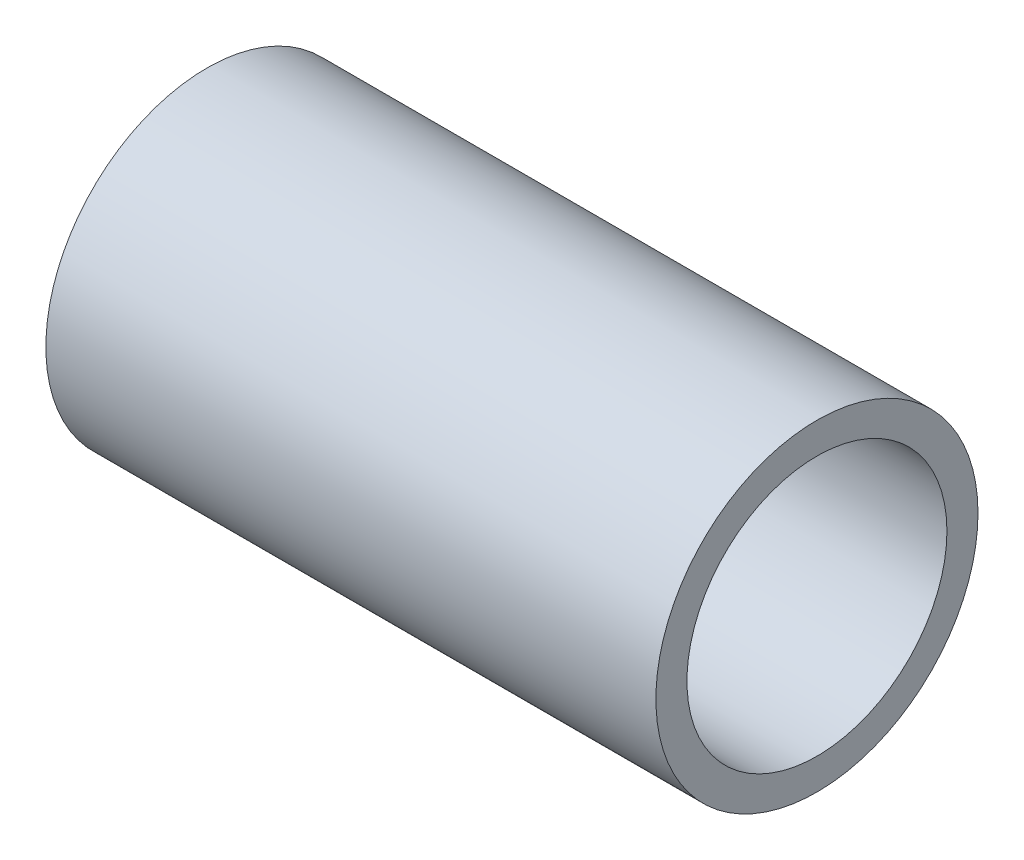
from build123d import *

# Parameters (mm, degrees)
SKETCH1_R           = 8.382
SKETCH1_R_2         = 6.765925
BOSS_EXTRUDE1_DEPTH = 31.75


with BuildPart() as part:
    # Sketch1 → Boss-Extrude1 (new body)
    with BuildSketch(Plane(origin=(0, 0, 0), x_dir=(0, 0, -1), z_dir=(1, 0, 0))):
        Circle(SKETCH1_R)
        Circle(SKETCH1_R_2, mode=Mode.SUBTRACT)
    extrude(amount=BOSS_EXTRUDE1_DEPTH)


solid = part.part
